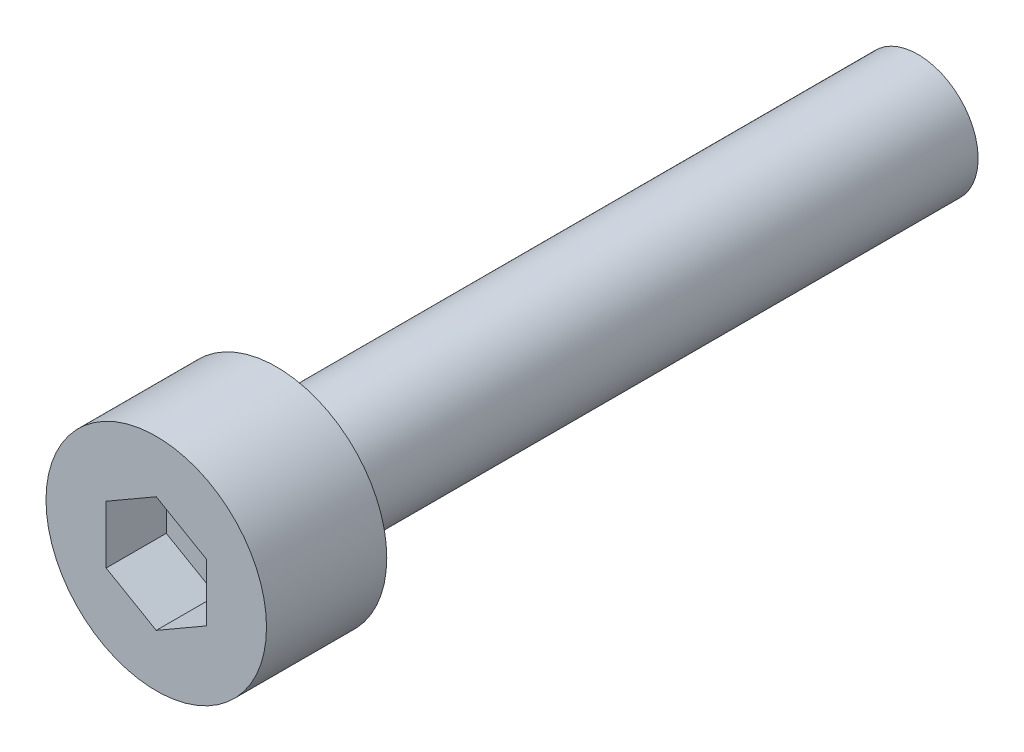
from build123d import *

# Parameters (mm, degrees)
SKETCH_1_R          = 2.75
EXTRUDE_1_DEPTH     = 3
CUT_EXTRUDE_1_DEPTH = 1.5
SKETCH_3_R          = 1.5
EXTRUDE_2_DEPTH     = 16


with BuildPart() as part:
    # 草图1 → 凸台-拉伸1 (new body)
    with BuildSketch(Plane.XY):
        Circle(SKETCH_1_R)
    extrude(amount=EXTRUDE_1_DEPTH)

    # 草图2 → 切除-拉伸1 (cut)
    with BuildSketch(Plane.XY.offset(3)):
        Polygon((0, -1.443375673), (1.25, -0.721687836), (1.25, 0.721687836), (0, 1.443375673), (-1.25, 0.721687836), (-1.25, -0.721687836), align=None)
    extrude(amount=-CUT_EXTRUDE_1_DEPTH, mode=Mode.SUBTRACT)

    # 草图3 → 凸台-拉伸2 (add)
    with BuildSketch(Plane(origin=(0, 0, 0), x_dir=(-1, 0, 0), z_dir=(0, 0, -1))):
        Circle(SKETCH_3_R)
    extrude(amount=EXTRUDE_2_DEPTH)


solid = part.part
